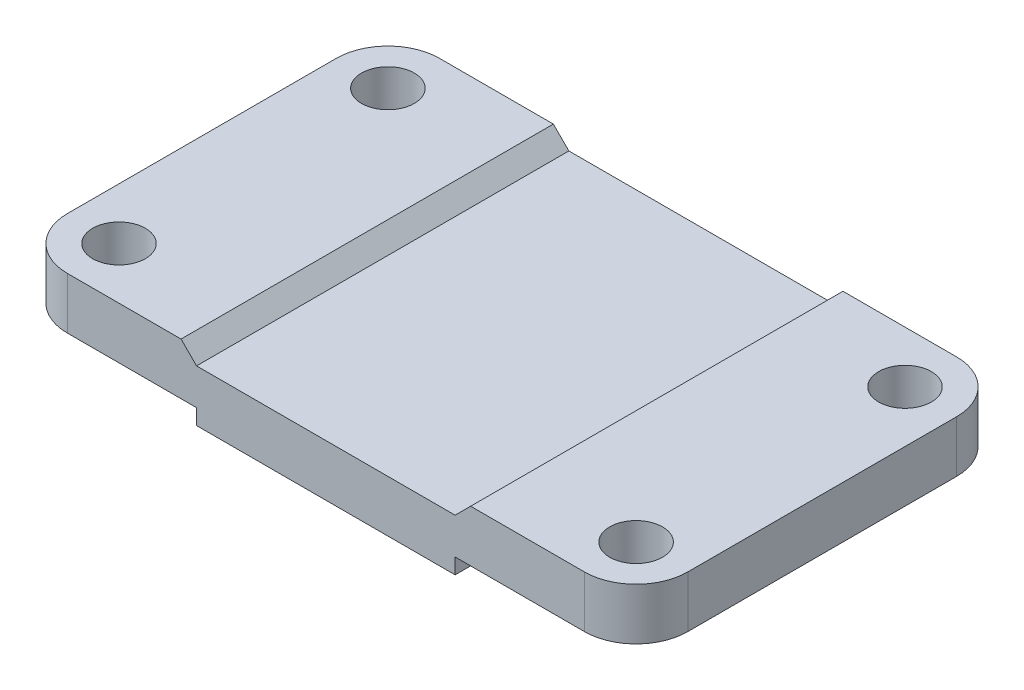
from build123d import *

# Parameters (mm, degrees)
SKETCH1_W              = 120
SKETCH1_H              = 72
BOSS_EXTRUDE1_DEPTH    = 10
FILLET1_R              = 10
M12_TAPPED_HOLE1_D     = 10.2
M12_TAPPED_HOLE1_DEPTH = 10
SKETCH6_W              = 50
SKETCH6_H              = 72
BOSS_EXTRUDE2_DEPTH    = 3
CUT_EXTRUDE1_DEPTH     = 73


with BuildPart() as part:
    # Sketch1 → Boss-Extrude1 (new body)
    with BuildSketch(Plane(origin=(0, 0, 0), x_dir=(1, 0, 0), z_dir=(0, 1, 0))):
        Rectangle(SKETCH1_W, SKETCH1_H)
    extrude(amount=BOSS_EXTRUDE1_DEPTH)

    # Fillet1
    fillet1_edges = [part.edges().sort_by_distance(p)[0] for p in [
        (60, 5, 36),
        (-60, 5, 36),
        (-60, 5, -36),
        (60, 5, -36),
    ]]
    fillet(fillet1_edges, radius=FILLET1_R)

    # M12 Tapped Hole1
    with Locations(Plane.XZ):
        with Locations((50, -26), (50, 26), (-50, 26), (-50, -26)):
            Hole(M12_TAPPED_HOLE1_D / 2, depth=M12_TAPPED_HOLE1_DEPTH)

    # Sketch6 → Boss-Extrude2 (add)
    with BuildSketch(Plane(origin=(0, 0, 0), x_dir=(1, 0, 0), z_dir=(0, 1, 0))):
        Rectangle(SKETCH6_W, SKETCH6_H)
    extrude(amount=-BOSS_EXTRUDE2_DEPTH)

    # Sketch11 → Cut-Extrude1 (cut, through all)
    with BuildSketch(Plane.XY.offset(36)):
        Polygon((-28, 10), (-25, 7), (25, 7), (28, 10), align=None)
    extrude(amount=-CUT_EXTRUDE1_DEPTH, mode=Mode.SUBTRACT)


solid = part.part
